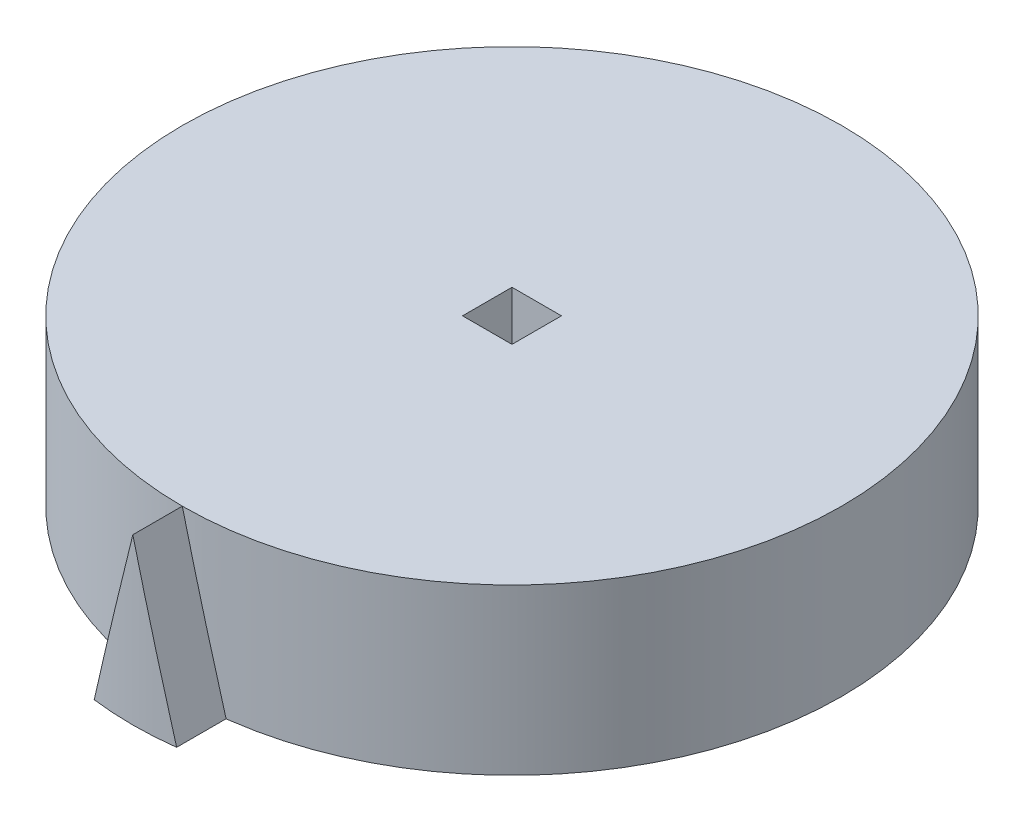
from build123d import *

# Parameters (mm, degrees)
SKETCH1_R                  = 20
SKETCH1_W                  = 3
SKETCH1_H                  = 3
BOSS_EXTRUDE1_DEPTH        = 10
BOSS_EXTRUDE2_REACH        = 35
BOSS_EXTRUDE2_START_RADIUS = 20
BOSS_EXTRUDE2_END_RADIUS   = 20


with BuildPart() as part:
    # Sketch1 → Boss-Extrude1 (new body)
    with BuildSketch(Plane(origin=(0, 0, 0), x_dir=(1, 0, 0), z_dir=(0, 1, 0))):
        with Locations(Location((0, 0, 0), (0, 0, 270))):
            Circle(SKETCH1_R)
        Rectangle(SKETCH1_W, SKETCH1_H, mode=Mode.SUBTRACT)
    extrude(amount=BOSS_EXTRUDE1_DEPTH)

    # Boss-Extrude2: from a cylinder face, 35 long prism both ways, kept between that surface and its translate by the depth
    boss_extrude2_start = Plane(origin=(0, 3.334512, 0), z_dir=(0, -1, 0)) * Cylinder(BOSS_EXTRUDE2_START_RADIUS, 111, mode=Mode.PRIVATE)
    boss_extrude2_end = Plane(origin=(0, 3.334512, 3), z_dir=(0, -1, 0)) * Cylinder(BOSS_EXTRUDE2_END_RADIUS, 111, mode=Mode.PRIVATE)
    # Sketch2 → Boss-Extrude2 (add, from a surface)
    with BuildSketch(Plane.XY, mode=Mode.PRIVATE) as boss_extrude2_sk1:
        Polygon((0, 10), (-2.5, 0.001767652), (2.5, 0.001767652), align=None)
    boss_extrude2_tool1 = extrude(boss_extrude2_sk1.sketch, amount=BOSS_EXTRUDE2_REACH, both=True, mode=Mode.PRIVATE)
    add(((boss_extrude2_tool1 - boss_extrude2_start) & boss_extrude2_end).solids().sort_by_distance((0, 3.334512, 21.421567))[0])


solid = part.part
